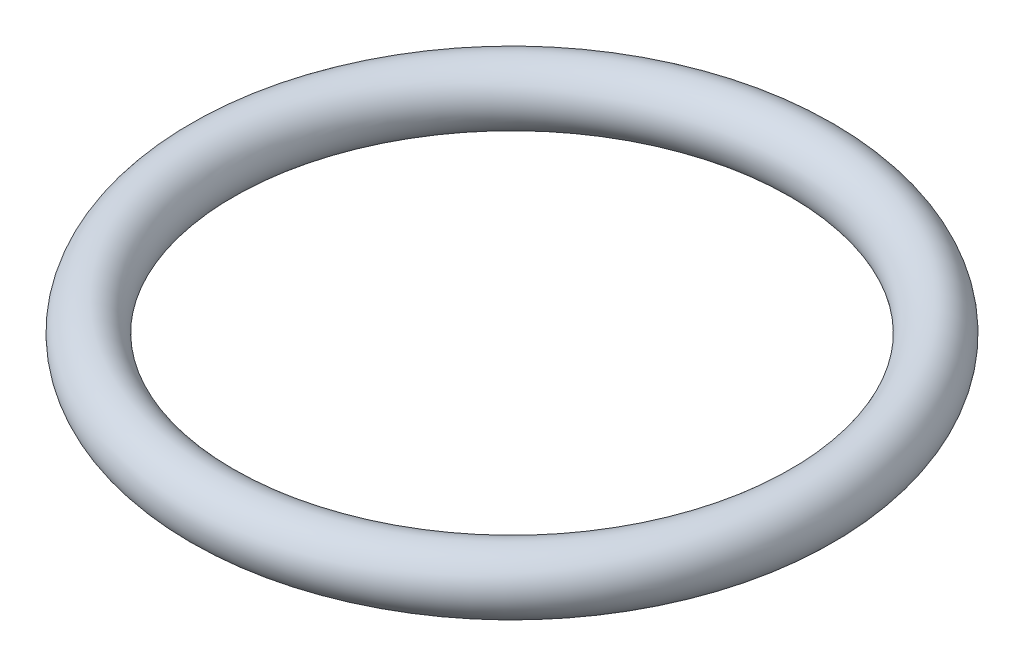
from build123d import *

# Parameters (mm, degrees)
ESQUISSE1_R = 1


with BuildPart() as part:
    # Esquisse1 → Révolution1 (revolve)
    with BuildSketch(Plane.XY, mode=Mode.PRIVATE) as r_volution1_sk:
        with Locations((10, -2.736392)):
            Circle(ESQUISSE1_R)
    revolve(r_volution1_sk.sketch.rotate(Axis((0, 34.708969072, 0), (0, -1, 0)), 90), axis=Axis((0, 34.708969072, 0), (0, -1, 0)))  # turned: the seam where the file's is


solid = part.part
